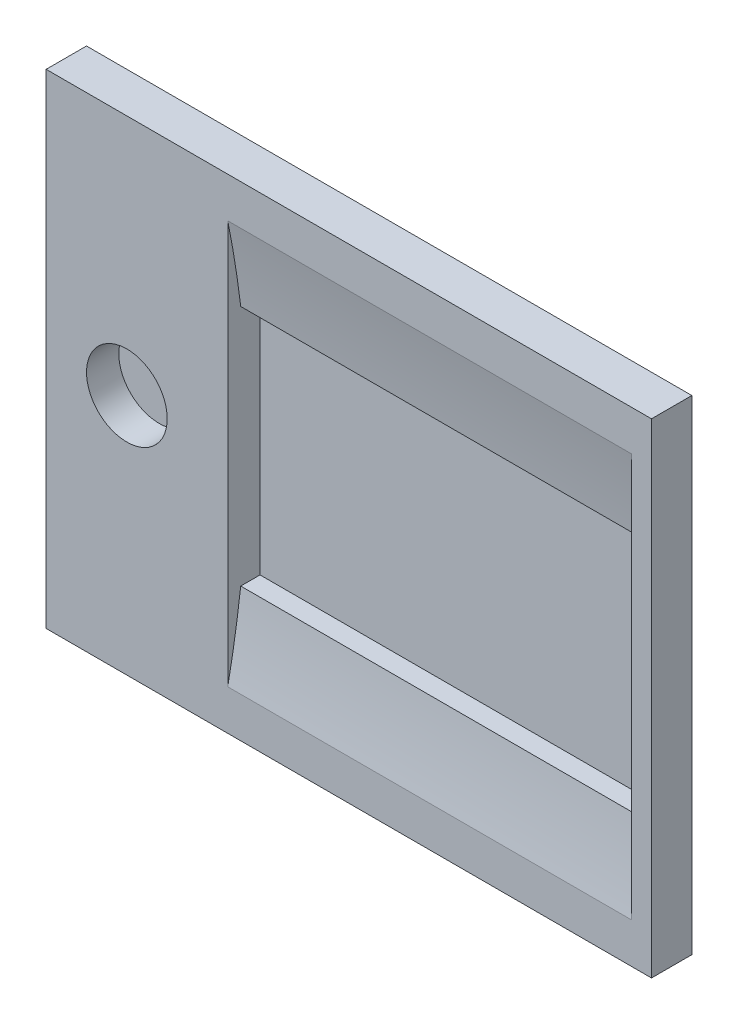
from build123d import *

# Parameters (mm, degrees)
SKETCH1_W           = 47.625
SKETCH1_H           = 38.1
BOSS_EXTRUDE1_DEPTH = 1.5875
SKETCH2_W           = 31.75
SKETCH2_H           = 19.05
SKETCH2_R           = 3.175
CUT_EXTRUDE1_DEPTH  = 2.54
CUT_EXTRUDE2_START  = -1.5875
CUT_EXTRUDE2_DEPTH  = 31.75


with BuildPart() as part:
    # Sketch1 → Boss-Extrude1 (new body, symmetric)
    with BuildSketch(Plane.XY):
        Rectangle(SKETCH1_W, SKETCH1_H)
    extrude(amount=BOSS_EXTRUDE1_DEPTH, both=True)

    # Sketch2 → Cut-Extrude1 (cut)
    with BuildSketch(Plane.XY.offset(1.5875)):
        with Locations((6.35, 0)):
            Rectangle(SKETCH2_W, SKETCH2_H)
        with Locations((-17.4625, 0)):
            Circle(SKETCH2_R)
    extrude(amount=-CUT_EXTRUDE1_DEPTH, mode=Mode.SUBTRACT)

    # Sketch4 → Cut-Extrude2 (cut)
    with BuildSketch(Plane(origin=(23.8125, 0, 0), x_dir=(0, 0, -1), z_dir=(1, 0, 0)).offset(CUT_EXTRUDE2_START)):
        with BuildLine():
            ThreePointArc((0, 0), (-0.397862257, 7.977088774), (-1.5875, 15.875))
            Line((-1.5875, 15.875), (-1.5875, -15.875))
            ThreePointArc((-1.5875, -15.875), (-0.397862257, -7.977088774), (0, 0))
        make_face()
    extrude(amount=-CUT_EXTRUDE2_DEPTH, mode=Mode.SUBTRACT)


solid = part.part
